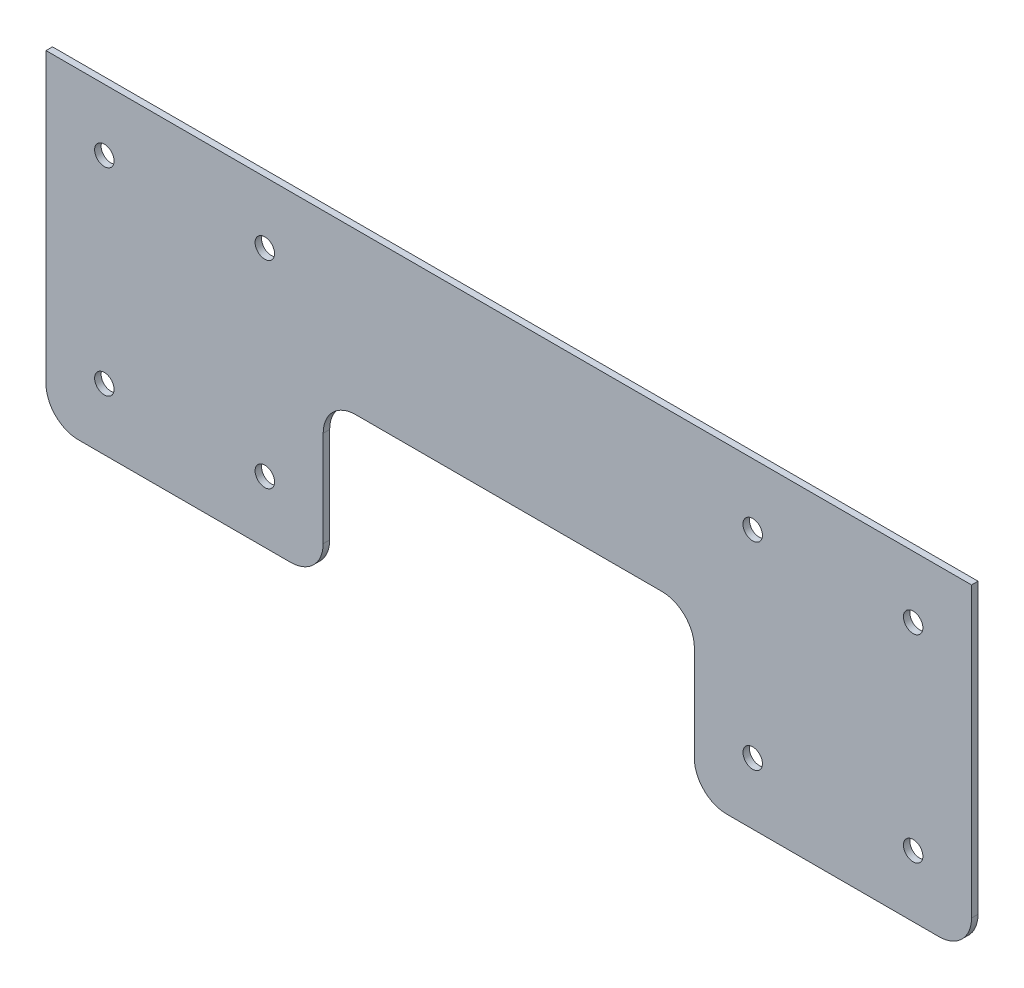
from build123d import *

# Parameters (mm, degrees)
SKETCH1_R           = 3
BOSS_EXTRUDE1_DEPTH = 2


with BuildPart() as part:
    # Sketch1 → Boss-Extrude1 (new body)
    with BuildSketch(Plane.XY):
        with BuildLine():
            Line((-142.75, 49.5), (-142.75, -39.5))
            ThreePointArc((-142.75, -39.5), (-139.821067812, -46.571067812), (-132.75, -49.5))
            Line((-132.75, -49.5), (-67.25, -49.5))
            ThreePointArc((-67.25, -49.5), (-60.178932188, -46.571067812), (-57.25, -39.5))
            Line((-57.25, -39.5), (-57.25, -10))
            ThreePointArc((-57.25, -10), (-54.321067812, -2.928932188), (-47.25, 0))
            Line((-47.25, 0), (47.25, 0))
            ThreePointArc((47.25, 0), (54.321067812, -2.928932188), (57.25, -10))
            Line((57.25, -10), (57.25, -39.5))
            ThreePointArc((57.25, -39.5), (60.178932188, -46.571067812), (67.25, -49.5))
            Line((67.25, -49.5), (132.75, -49.5))
            ThreePointArc((132.75, -49.5), (139.821067812, -46.571067812), (142.75, -39.5))
            Line((142.75, -39.5), (142.75, 49.5))
            Line((142.75, 49.5), (-142.75, 49.5))
        make_face()
        with Locations((124.75, 30.5)):
            Circle(SKETCH1_R, mode=Mode.SUBTRACT)
        with Locations((124.75, -30.5)):
            Circle(SKETCH1_R, mode=Mode.SUBTRACT)
        with Locations((75.25, -30.5)):
            Circle(SKETCH1_R, mode=Mode.SUBTRACT)
        with Locations((75.25, 30.5)):
            Circle(SKETCH1_R, mode=Mode.SUBTRACT)
        with Locations((-75.25, -30.5)):
            Circle(SKETCH1_R, mode=Mode.SUBTRACT)
        with Locations((-75.25, 30.5)):
            Circle(SKETCH1_R, mode=Mode.SUBTRACT)
        with Locations((-124.75, 30.5)):
            Circle(SKETCH1_R, mode=Mode.SUBTRACT)
        with Locations((-124.75, -30.5)):
            Circle(SKETCH1_R, mode=Mode.SUBTRACT)
    extrude(amount=BOSS_EXTRUDE1_DEPTH)


solid = part.part
